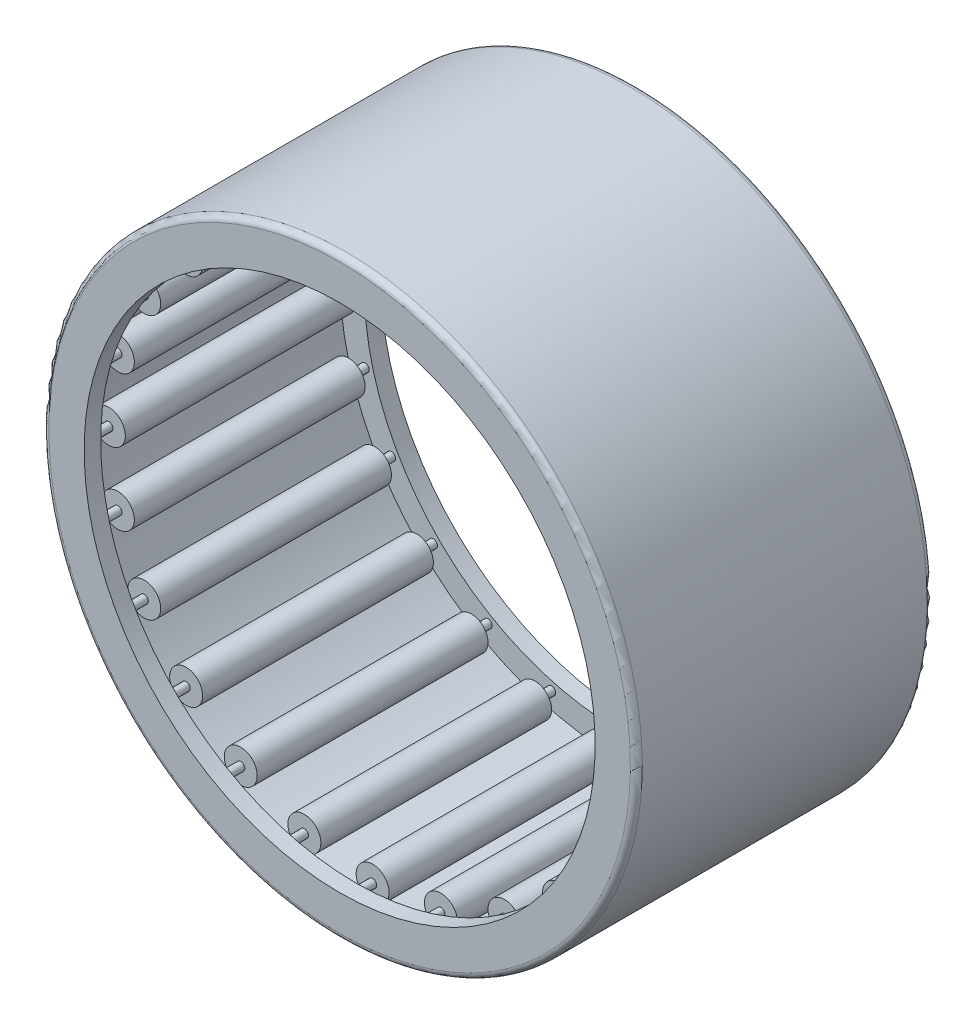
from build123d import *

# Parameters (mm, degrees)
SKETCH2_W         = 14.816666666
SKETCH2_H         = 0.79375
SKETCH3_W         = 16.933333334
SKETCH3_H         = 0.264583334
CIRPATTERN1_COUNT = 24
FILLET1_R         = 0.381


with BuildPart() as part:
    # Sketch1 → Revolve1 (revolve)
    with BuildSketch(Plane(origin=(0, 0, 0), x_dir=(0, 0, -1), z_dir=(1, 0, 0))):
        Polygon((-9.525, 19.05), (9.525, 19.05), (9.525, 16.404166667), (8.466666667, 16.404166667), (8.466666667, 17.991666667), (-8.466666667, 17.991666667), (-8.466666667, 16.404166667), (-9.525, 16.404166667), align=None)
    revolve(axis=Axis((0, 0, 9.525), (0, 0, -1)))

    # Fillet1
    fillet1_edges = [part.edges().sort_by_distance(p)[0] for p in [
        (0, -19.05, -9.525),
        (0, -19.05, 9.525),
    ]]
    fillet(fillet1_edges, radius=FILLET1_R)


with BuildPart() as body_2:
    # Sketch2 → Revolve2 (revolve)
    with BuildSketch(Plane(origin=(0, 0, 0), x_dir=(0, 0, -1), z_dir=(1, 0, 0))):
        with Locations((0, 17.594791667)):
            Rectangle(SKETCH2_W, SKETCH2_H)
    revolve(axis=Axis((0, 16.933333333, 7.408333333), (0, 0, -1)))


with BuildPart() as body_3:
    # Sketch3 → Revolve3 (revolve)
    with BuildSketch(Plane(origin=(0, 0, 0), x_dir=(0, 0, -1), z_dir=(1, 0, 0))):
        with Locations((0, 17.065625)):
            Rectangle(SKETCH3_W, SKETCH3_H)
    revolve(axis=Axis((0, 16.933333333, 8.466666667), (0, 0, -1)))


with BuildPart() as cirpattern1_1:
    # CirPattern1: pattern copy
    add(body_2.part.rotate(Axis((0, 0, -9.525), (0, 0, 1)), 1 * 360 / CIRPATTERN1_COUNT))


with BuildPart() as cirpattern1_2:
    # CirPattern1: pattern copy
    add(body_2.part.rotate(Axis((0, 0, -9.525), (0, 0, 1)), 2 * 360 / CIRPATTERN1_COUNT))


with BuildPart() as cirpattern1_3:
    # CirPattern1: pattern copy
    add(body_2.part.rotate(Axis((0, 0, -9.525), (0, 0, 1)), 3 * 360 / CIRPATTERN1_COUNT))


with BuildPart() as cirpattern1_4:
    # CirPattern1: pattern copy
    add(body_2.part.rotate(Axis((0, 0, -9.525), (0, 0, 1)), 4 * 360 / CIRPATTERN1_COUNT))


with BuildPart() as cirpattern1_5:
    # CirPattern1: pattern copy
    add(body_2.part.rotate(Axis((0, 0, -9.525), (0, 0, 1)), 5 * 360 / CIRPATTERN1_COUNT))


with BuildPart() as cirpattern1_6:
    # CirPattern1: pattern copy
    add(body_2.part.rotate(Axis((0, 0, -9.525), (0, 0, 1)), 6 * 360 / CIRPATTERN1_COUNT))


with BuildPart() as cirpattern1_7:
    # CirPattern1: pattern copy
    add(body_2.part.rotate(Axis((0, 0, -9.525), (0, 0, 1)), 7 * 360 / CIRPATTERN1_COUNT))


with BuildPart() as cirpattern1_8:
    # CirPattern1: pattern copy
    add(body_2.part.rotate(Axis((0, 0, -9.525), (0, 0, 1)), 8 * 360 / CIRPATTERN1_COUNT))


with BuildPart() as cirpattern1_9:
    # CirPattern1: pattern copy
    add(body_2.part.rotate(Axis((0, 0, -9.525), (0, 0, 1)), 9 * 360 / CIRPATTERN1_COUNT))


with BuildPart() as cirpattern1_10:
    # CirPattern1: pattern copy
    add(body_2.part.rotate(Axis((0, 0, -9.525), (0, 0, 1)), 10 * 360 / CIRPATTERN1_COUNT))


with BuildPart() as cirpattern1_11:
    # CirPattern1: pattern copy
    add(body_2.part.rotate(Axis((0, 0, -9.525), (0, 0, 1)), 11 * 360 / CIRPATTERN1_COUNT))


with BuildPart() as cirpattern1_12:
    # CirPattern1: pattern copy
    add(body_2.part.rotate(Axis((0, 0, -9.525), (0, 0, 1)), 12 * 360 / CIRPATTERN1_COUNT))


with BuildPart() as cirpattern1_13:
    # CirPattern1: pattern copy
    add(body_2.part.rotate(Axis((0, 0, -9.525), (0, 0, 1)), 13 * 360 / CIRPATTERN1_COUNT))


with BuildPart() as cirpattern1_14:
    # CirPattern1: pattern copy
    add(body_2.part.rotate(Axis((0, 0, -9.525), (0, 0, 1)), 14 * 360 / CIRPATTERN1_COUNT))


with BuildPart() as cirpattern1_15:
    # CirPattern1: pattern copy
    add(body_2.part.rotate(Axis((0, 0, -9.525), (0, 0, 1)), 15 * 360 / CIRPATTERN1_COUNT))


with BuildPart() as cirpattern1_16:
    # CirPattern1: pattern copy
    add(body_2.part.rotate(Axis((0, 0, -9.525), (0, 0, 1)), 16 * 360 / CIRPATTERN1_COUNT))


with BuildPart() as cirpattern1_17:
    # CirPattern1: pattern copy
    add(body_2.part.rotate(Axis((0, 0, -9.525), (0, 0, 1)), 17 * 360 / CIRPATTERN1_COUNT))


with BuildPart() as cirpattern1_18:
    # CirPattern1: pattern copy
    add(body_2.part.rotate(Axis((0, 0, -9.525), (0, 0, 1)), 18 * 360 / CIRPATTERN1_COUNT))


with BuildPart() as cirpattern1_19:
    # CirPattern1: pattern copy
    add(body_2.part.rotate(Axis((0, 0, -9.525), (0, 0, 1)), 19 * 360 / CIRPATTERN1_COUNT))


with BuildPart() as cirpattern1_20:
    # CirPattern1: pattern copy
    add(body_2.part.rotate(Axis((0, 0, -9.525), (0, 0, 1)), 20 * 360 / CIRPATTERN1_COUNT))


with BuildPart() as cirpattern1_21:
    # CirPattern1: pattern copy
    add(body_2.part.rotate(Axis((0, 0, -9.525), (0, 0, 1)), 21 * 360 / CIRPATTERN1_COUNT))


with BuildPart() as cirpattern1_22:
    # CirPattern1: pattern copy
    add(body_2.part.rotate(Axis((0, 0, -9.525), (0, 0, 1)), 22 * 360 / CIRPATTERN1_COUNT))


with BuildPart() as cirpattern1_23:
    # CirPattern1: pattern copy
    add(body_2.part.rotate(Axis((0, 0, -9.525), (0, 0, 1)), 23 * 360 / CIRPATTERN1_COUNT))


with BuildPart() as cirpattern1_24:
    # CirPattern1: pattern copy
    add(body_3.part.rotate(Axis((0, 0, -9.525), (0, 0, 1)), 1 * 360 / CIRPATTERN1_COUNT))


with BuildPart() as cirpattern1_25:
    # CirPattern1: pattern copy
    add(body_3.part.rotate(Axis((0, 0, -9.525), (0, 0, 1)), 2 * 360 / CIRPATTERN1_COUNT))


with BuildPart() as cirpattern1_26:
    # CirPattern1: pattern copy
    add(body_3.part.rotate(Axis((0, 0, -9.525), (0, 0, 1)), 3 * 360 / CIRPATTERN1_COUNT))


with BuildPart() as cirpattern1_27:
    # CirPattern1: pattern copy
    add(body_3.part.rotate(Axis((0, 0, -9.525), (0, 0, 1)), 4 * 360 / CIRPATTERN1_COUNT))


with BuildPart() as cirpattern1_28:
    # CirPattern1: pattern copy
    add(body_3.part.rotate(Axis((0, 0, -9.525), (0, 0, 1)), 5 * 360 / CIRPATTERN1_COUNT))


with BuildPart() as cirpattern1_29:
    # CirPattern1: pattern copy
    add(body_3.part.rotate(Axis((0, 0, -9.525), (0, 0, 1)), 6 * 360 / CIRPATTERN1_COUNT))


with BuildPart() as cirpattern1_30:
    # CirPattern1: pattern copy
    add(body_3.part.rotate(Axis((0, 0, -9.525), (0, 0, 1)), 7 * 360 / CIRPATTERN1_COUNT))


with BuildPart() as cirpattern1_31:
    # CirPattern1: pattern copy
    add(body_3.part.rotate(Axis((0, 0, -9.525), (0, 0, 1)), 8 * 360 / CIRPATTERN1_COUNT))


with BuildPart() as cirpattern1_32:
    # CirPattern1: pattern copy
    add(body_3.part.rotate(Axis((0, 0, -9.525), (0, 0, 1)), 9 * 360 / CIRPATTERN1_COUNT))


with BuildPart() as cirpattern1_33:
    # CirPattern1: pattern copy
    add(body_3.part.rotate(Axis((0, 0, -9.525), (0, 0, 1)), 10 * 360 / CIRPATTERN1_COUNT))


with BuildPart() as cirpattern1_34:
    # CirPattern1: pattern copy
    add(body_3.part.rotate(Axis((0, 0, -9.525), (0, 0, 1)), 11 * 360 / CIRPATTERN1_COUNT))


with BuildPart() as cirpattern1_35:
    # CirPattern1: pattern copy
    add(body_3.part.rotate(Axis((0, 0, -9.525), (0, 0, 1)), 12 * 360 / CIRPATTERN1_COUNT))


with BuildPart() as cirpattern1_36:
    # CirPattern1: pattern copy
    add(body_3.part.rotate(Axis((0, 0, -9.525), (0, 0, 1)), 13 * 360 / CIRPATTERN1_COUNT))


with BuildPart() as cirpattern1_37:
    # CirPattern1: pattern copy
    add(body_3.part.rotate(Axis((0, 0, -9.525), (0, 0, 1)), 14 * 360 / CIRPATTERN1_COUNT))


with BuildPart() as cirpattern1_38:
    # CirPattern1: pattern copy
    add(body_3.part.rotate(Axis((0, 0, -9.525), (0, 0, 1)), 15 * 360 / CIRPATTERN1_COUNT))


with BuildPart() as cirpattern1_39:
    # CirPattern1: pattern copy
    add(body_3.part.rotate(Axis((0, 0, -9.525), (0, 0, 1)), 16 * 360 / CIRPATTERN1_COUNT))


with BuildPart() as cirpattern1_40:
    # CirPattern1: pattern copy
    add(body_3.part.rotate(Axis((0, 0, -9.525), (0, 0, 1)), 17 * 360 / CIRPATTERN1_COUNT))


with BuildPart() as cirpattern1_41:
    # CirPattern1: pattern copy
    add(body_3.part.rotate(Axis((0, 0, -9.525), (0, 0, 1)), 18 * 360 / CIRPATTERN1_COUNT))


with BuildPart() as cirpattern1_42:
    # CirPattern1: pattern copy
    add(body_3.part.rotate(Axis((0, 0, -9.525), (0, 0, 1)), 19 * 360 / CIRPATTERN1_COUNT))


with BuildPart() as cirpattern1_43:
    # CirPattern1: pattern copy
    add(body_3.part.rotate(Axis((0, 0, -9.525), (0, 0, 1)), 20 * 360 / CIRPATTERN1_COUNT))


with BuildPart() as cirpattern1_44:
    # CirPattern1: pattern copy
    add(body_3.part.rotate(Axis((0, 0, -9.525), (0, 0, 1)), 21 * 360 / CIRPATTERN1_COUNT))


with BuildPart() as cirpattern1_45:
    # CirPattern1: pattern copy
    add(body_3.part.rotate(Axis((0, 0, -9.525), (0, 0, 1)), 22 * 360 / CIRPATTERN1_COUNT))


with BuildPart() as cirpattern1_46:
    # CirPattern1: pattern copy
    add(body_3.part.rotate(Axis((0, 0, -9.525), (0, 0, 1)), 23 * 360 / CIRPATTERN1_COUNT))


solid = Compound([part.part, body_2.part, body_3.part, cirpattern1_1.part, cirpattern1_2.part, cirpattern1_3.part, cirpattern1_4.part, cirpattern1_5.part, cirpattern1_6.part, cirpattern1_7.part, cirpattern1_8.part, cirpattern1_9.part, cirpattern1_10.part, cirpattern1_11.part, cirpattern1_12.part, cirpattern1_13.part, cirpattern1_14.part, cirpattern1_15.part, cirpattern1_16.part, cirpattern1_17.part, cirpattern1_18.part, cirpattern1_19.part, cirpattern1_20.part, cirpattern1_21.part, cirpattern1_22.part, cirpattern1_23.part, cirpattern1_24.part, cirpattern1_25.part, cirpattern1_26.part, cirpattern1_27.part, cirpattern1_28.part, cirpattern1_29.part, cirpattern1_30.part, cirpattern1_31.part, cirpattern1_32.part, cirpattern1_33.part, cirpattern1_34.part, cirpattern1_35.part, cirpattern1_36.part, cirpattern1_37.part, cirpattern1_38.part, cirpattern1_39.part, cirpattern1_40.part, cirpattern1_41.part, cirpattern1_42.part, cirpattern1_43.part, cirpattern1_44.part, cirpattern1_45.part, cirpattern1_46.part])
